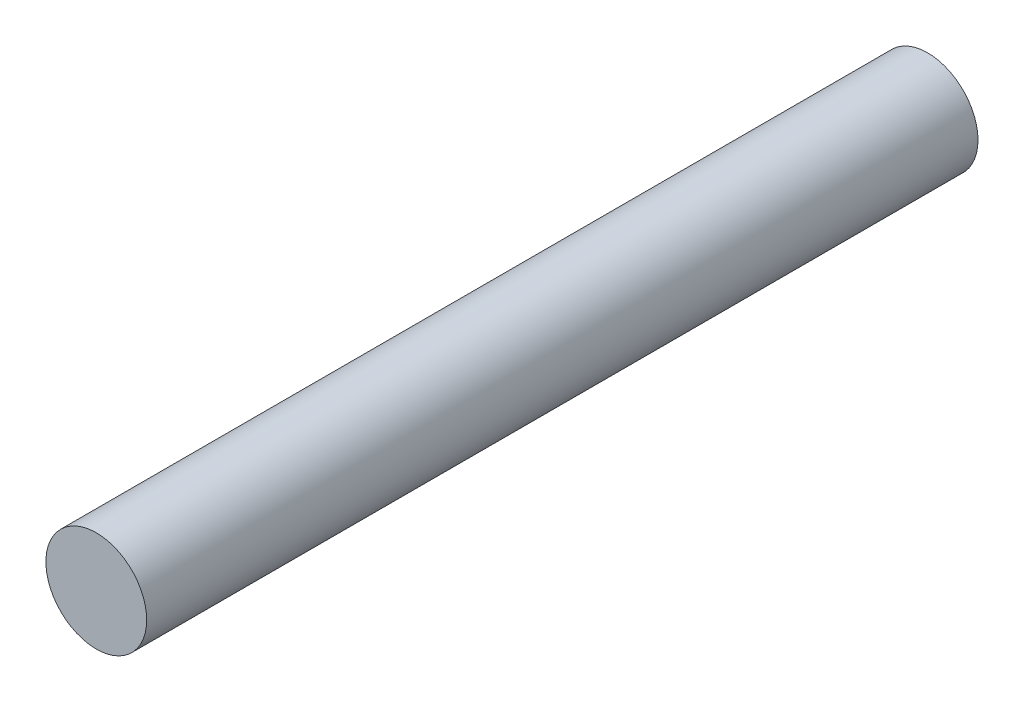
from build123d import *

# Parameters (mm, degrees)
ESBO_O1_R                = 120
RESSALTO_EXTRUS_O1_DEPTH = 1980


with BuildPart() as part:
    # Esboço1 → Ressalto-extrusão1 (new body)
    with BuildSketch(Plane.XY):
        Circle(ESBO_O1_R)
    extrude(amount=RESSALTO_EXTRUS_O1_DEPTH)


solid = part.part
